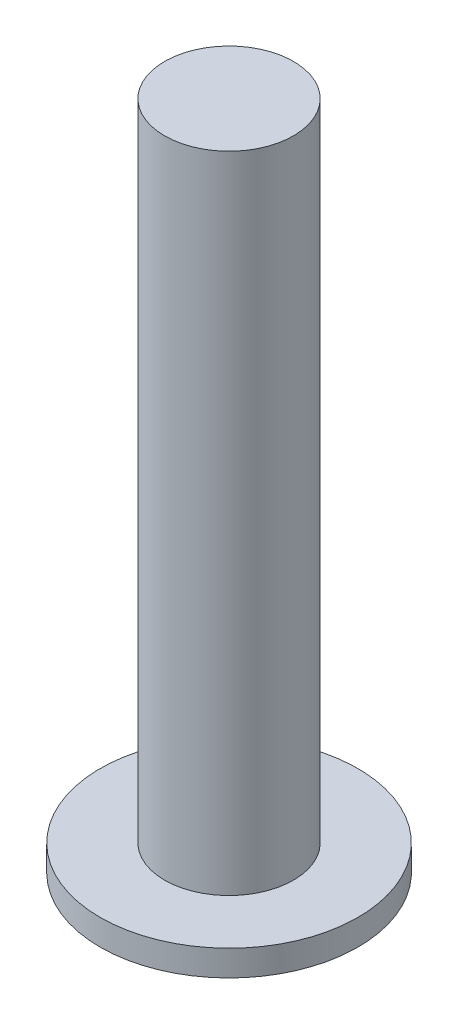
from build123d import *

# Parameters (mm, degrees)
SKETCH1_R           = 50
BOSS_EXTRUDE1_DEPTH = 10
SKETCH2_R           = 25
BOSS_EXTRUDE2_DEPTH = 250


with BuildPart() as part:
    # Sketch1 → Boss-Extrude1 (new body)
    with BuildSketch(Plane(origin=(0, 0, 0), x_dir=(1, 0, 0), z_dir=(0, 1, 0))):
        Circle(SKETCH1_R)
    extrude(amount=BOSS_EXTRUDE1_DEPTH)

    # Sketch2 → Boss-Extrude2 (add)
    with BuildSketch(Plane(origin=(0, 10, 0), x_dir=(1, 0, 0), z_dir=(0, 1, 0))):
        Circle(SKETCH2_R)
    extrude(amount=BOSS_EXTRUDE2_DEPTH)


solid = part.part
